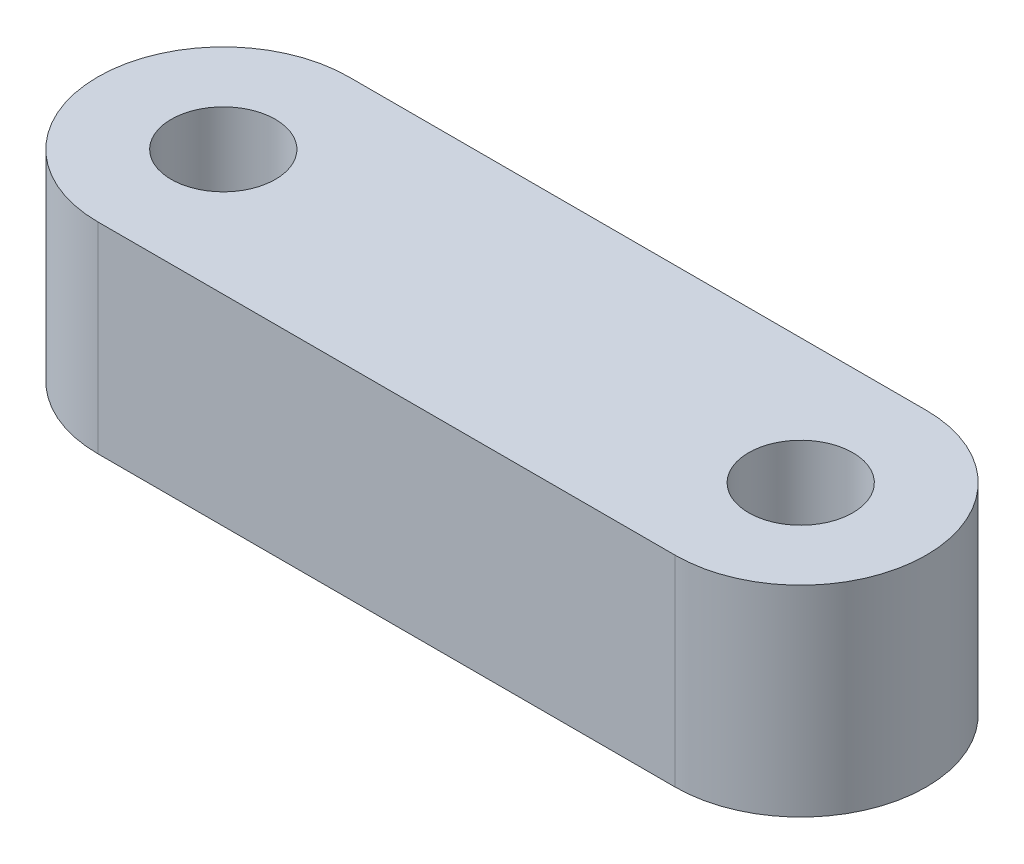
from build123d import *

# Parameters (mm, degrees)
EXTRUDE_1_DEPTH = 8


with BuildPart() as part:
    # 草图1 → 凸台-拉伸1 (new body)
    with BuildSketch(Plane(origin=(0, 0, 0), x_dir=(1, 0, 0), z_dir=(0, 1, 0))):
        with BuildLine():
            Line((0, 5), (23, 5))
            ThreePointArc((23, 5), (28, 0), (23, -5))
            Line((23, -5), (0, -5))
            ThreePointArc((0, -5), (-5, 0), (0, 5))
        make_face()
    extrude(amount=EXTRUDE_1_DEPTH)

    # 草图2 → 切除-旋转1 (revolve, cut)
    with BuildSketch(Plane.XY):
        Polygon((0, 8), (-2.075, 8), (-2.075, 3.5), (-3.75, 3.5), (-3.75, 0), (0, 0), align=None)
    revolve(axis=Axis((0, 0, 0), (0, 1, 0)), mode=Mode.SUBTRACT)

    # 草图3 → 切除-旋转2 (revolve, cut)
    with BuildSketch(Plane.XY):
        Polygon((23, 8), (20.925, 8), (20.925, 3.5), (19.25, 3.5), (19.25, 0), (23, 0), align=None)
    revolve(axis=Axis((23, 0, 0), (0, 1, 0)), mode=Mode.SUBTRACT)


solid = part.part
